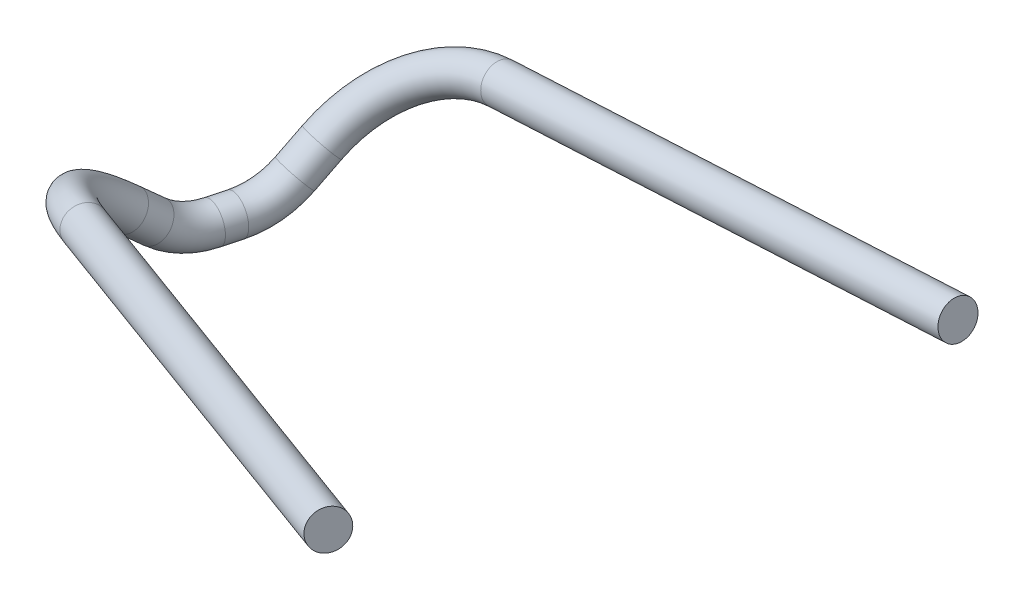
from build123d import *

# Parameters (mm, degrees)
SWEEP1_PROFILE_R = 0.75


with BuildPart() as part:
    # Sweep1: sweep along a curve in space
    with BuildLine() as sweep1_path:
        Line((-96.760776121, -3.47025774, 78.252711823), (-78.084348541, -0.522963163, 86.961878631))
        ThreePointArc((-96.760776121, -3.47025774, 78.252711823), (-99.112397911, -4.596881054, 76.226314182), (-99.548244883, -6.60263734, 73.639294338))
        Line((-99.548244883, -6.60263734, 73.639294338), (-99.328473076, -7.317696757, 72.819094788))
        ThreePointArc((-98.82832928, -8.022963163, 70.95253273), (-99.09453566, -7.841136399, 71.946028463), (-99.328473076, -7.317696757, 72.819094788))
        Line((-98.627122104, -8.022963163, 70.201617327), (-98.82832928, -8.022963163, 70.95253273))
        ThreePointArc((-98.627122104, -8.022963163, 70.201617327), (-98.353918152, -7.831121447, 69.182006297), (-98.115655477, -7.280131794, 68.292797886))
        Line((-98.115655477, -7.280131794, 68.292797886), (-97.882684409, -6.49206537, 67.423338024))
        ThreePointArc((-93.143377561, -3.311786612, 64.859921351), (-96.209258102, -4.441131936, 65.426107931), (-97.882684409, -6.49206537, 67.423338024))
        Line((-93.143377561, -3.311786612, 64.859921351), (-72.649148593, -0.522963163, 66.677436279))
    # Sweep1 profile (on start of the path) → Sweep1 (sweep)
    with BuildSketch(Plane(origin=(-72.649148593, -0.522963163, 66.677436279), x_dir=(0.13483580164041467, -0.9908679561858819, 0), z_dir=(-0.9870642774001727, -0.1343182028271198, -0.08753703598916203))):
        Circle(SWEEP1_PROFILE_R)
    sweep(path=sweep1_path.line)


solid = part.part
